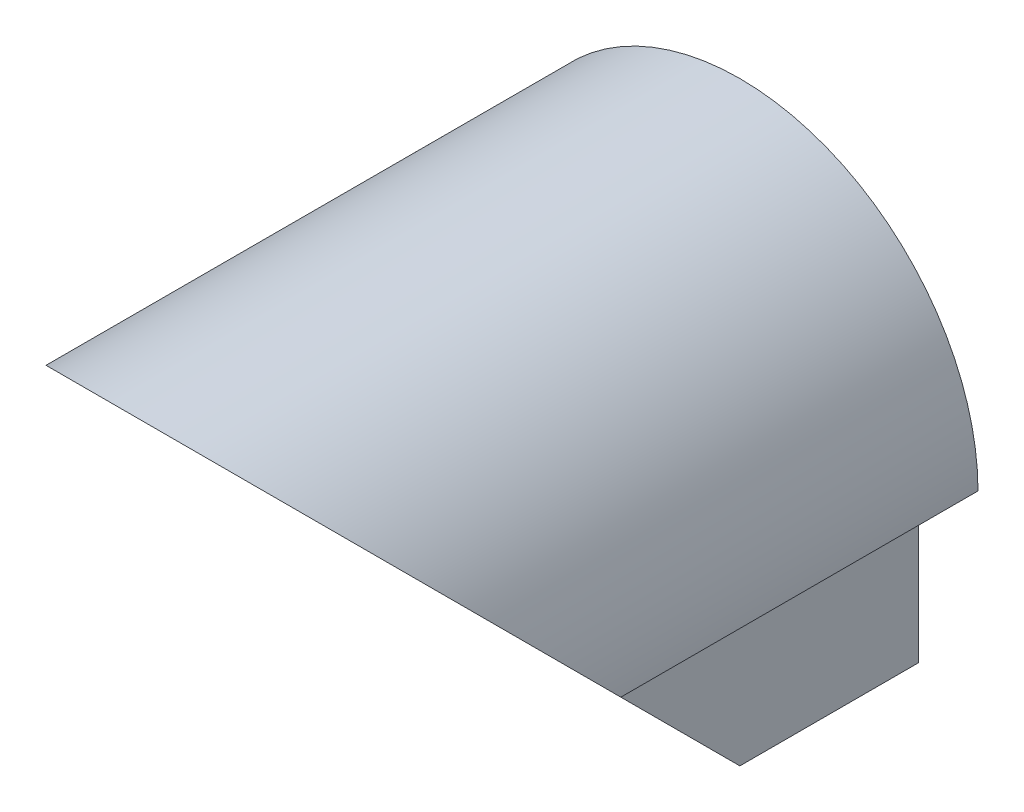
from build123d import *

# Parameters (mm, degrees)
SKETCH2_W           = 4
SKETCH2_H           = 2
BOSS_EXTRUDE1_DEPTH = 5
CUT_EXTRUDE1_DEPTH  = 4


with BuildPart() as part:
    # Sketch2 → Boss-Extrude1 (new body, symmetric)
    with BuildSketch(Plane.XY):
        with BuildLine():
            Line((-4, -1), (-3, -1))
            Line((-3, -1), (-3, -4))
            Line((-3, -4), (-2, -4))
            Line((-2, -4), (-2, -3))
            Line((-2, -3), (-1, -3))
            Line((-1, -3), (-1, -2))
            Line((-1, -2), (1, -2))
            Line((1, -2), (1, -3))
            Line((1, -3), (2, -3))
            Line((2, -3), (2, -4))
            Line((2, -4), (3, -4))
            Line((3, -4), (3, -1))
            Line((3, -1), (4, -1))
            ThreePointArc((4, -1), (0, 3), (-4, -1))
        make_face()
        Rectangle(SKETCH2_W, SKETCH2_H, mode=Mode.SUBTRACT)
    extrude(amount=BOSS_EXTRUDE1_DEPTH, both=True)

    # Sketch3 → Cut-Extrude1 (cut, symmetric)
    with BuildSketch(Plane(origin=(0, 0, 0), x_dir=(0, 0, -1), z_dir=(1, 0, 0))):
        Polygon((-5, 3), (2, -4), (-5, -4), align=None)
    extrude(amount=CUT_EXTRUDE1_DEPTH, both=True, mode=Mode.SUBTRACT)


solid = part.part
